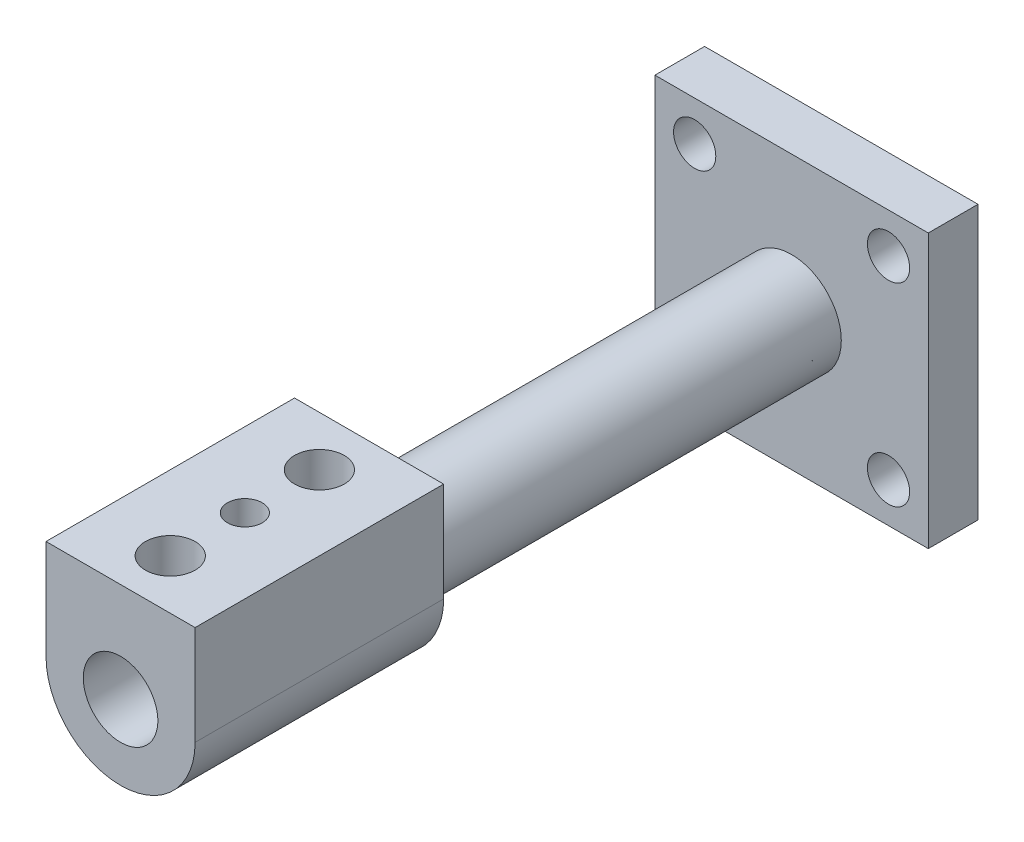
from build123d import *

# Parameters (mm, degrees)
SKETCH1_W               = 55
SKETCH1_H               = 55
BOSS_EXTRUDE1_DEPTH     = 10
SKETCH2_R               = 10
BOSS_EXTRUDE2_DEPTH     = 85
BOSS_EXTRUDE3_DEPTH     = 50
SKETCH4_R               = 7.5
CUT_EXTRUDE1_DEPTH      = 1
CUT_EXTRUDE1_DEPTH_BACK = 146
CUT_EXTRUDE2_REACH      = 49.5
SKETCH5_R               = 5
SKETCH5_R_2             = 3.5
SKETCH6_R               = 4.25
CUT_EXTRUDE3_DEPTH      = 50


with BuildPart() as part:
    # Sketch1 → Boss-Extrude1 (new body)
    with BuildSketch(Plane.XY):
        Rectangle(SKETCH1_W, SKETCH1_H)
    extrude(amount=BOSS_EXTRUDE1_DEPTH)

    # Sketch2 → Boss-Extrude2 (add)
    with BuildSketch(Plane.XY.offset(10)):
        Circle(SKETCH2_R)
    extrude(amount=BOSS_EXTRUDE2_DEPTH)

    # Sketch3 → Boss-Extrude3 (add)
    with BuildSketch(Plane.XY.offset(95)):
        with BuildLine():
            Line((-15, 0), (-15, 20))
            Line((-15, 20), (15, 20))
            Line((15, 20), (15, 0))
            ThreePointArc((15, 0), (0, -15), (-15, 0))
        make_face()
    extrude(amount=BOSS_EXTRUDE3_DEPTH)

    # Sketch4 → Cut-Extrude1 (cut, two sides)
    with BuildSketch(Plane(origin=(0, 0, 0), x_dir=(-1, 0, 0), z_dir=(0, 0, -1))) as cut_extrude1_sk:
        Circle(SKETCH4_R)
    extrude(amount=CUT_EXTRUDE1_DEPTH, mode=Mode.SUBTRACT)
    extrude(cut_extrude1_sk.sketch, amount=-CUT_EXTRUDE1_DEPTH_BACK, mode=Mode.SUBTRACT)

    # Sketch5 → Cut-Extrude2 (cut, up to next)
    with BuildSketch(Plane(origin=(0, 20, 0), x_dir=(1, 0, 0), z_dir=(0, 1, 0)), mode=Mode.PRIVATE) as cut_extrude2_sk1:
        with Locations((0, -135)):
            Circle(SKETCH5_R)
    cut_extrude2_tool1 = extrude(cut_extrude2_sk1.sketch, amount=-CUT_EXTRUDE2_REACH, mode=Mode.PRIVATE) & part.part
    add(cut_extrude2_tool1.solids().sort_by_distance((0, 20, 135))[0], mode=Mode.SUBTRACT)
    # Sketch5 → Cut-Extrude2 (cut, up to next)
    with BuildSketch(Plane(origin=(0, 20, 0), x_dir=(1, 0, 0), z_dir=(0, 1, 0)), mode=Mode.PRIVATE) as cut_extrude2_sk2:
        with Locations((0, -120)):
            Circle(SKETCH5_R_2)
    cut_extrude2_tool2 = extrude(cut_extrude2_sk2.sketch, amount=-CUT_EXTRUDE2_REACH, mode=Mode.PRIVATE) & part.part
    add(cut_extrude2_tool2.solids().sort_by_distance((0, 20, 120))[0], mode=Mode.SUBTRACT)
    # Sketch5 → Cut-Extrude2 (cut, up to next)
    with BuildSketch(Plane(origin=(0, 20, 0), x_dir=(1, 0, 0), z_dir=(0, 1, 0)), mode=Mode.PRIVATE) as cut_extrude2_sk3:
        with Locations((0, -105)):
            Circle(SKETCH5_R)
    cut_extrude2_tool3 = extrude(cut_extrude2_sk3.sketch, amount=-CUT_EXTRUDE2_REACH, mode=Mode.PRIVATE) & part.part
    add(cut_extrude2_tool3.solids().sort_by_distance((0, 20, 105))[0], mode=Mode.SUBTRACT)

    # Sketch6 → Cut-Extrude3 (cut)
    with BuildSketch(Plane.XY.offset(10)):
        with Locations((-19.5, 19.5)):
            Circle(SKETCH6_R)
        with Locations((19.5, 19.5)):
            Circle(SKETCH6_R)
        with Locations((19.5, -19.5)):
            Circle(SKETCH6_R)
        with Locations((-19.5, -19.5)):
            Circle(SKETCH6_R)
    extrude(amount=-CUT_EXTRUDE3_DEPTH, mode=Mode.SUBTRACT)


solid = part.part
